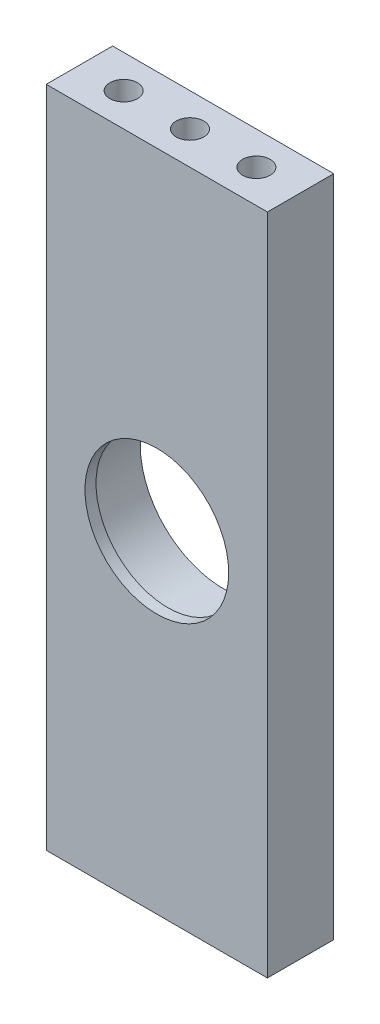
from build123d import *

# Parameters (mm, degrees)
SKETCH_1_R             = 7.5
EXTRUDE_1_DEPTH        = 6
SKETCH_2_R             = 7.5
SKETCH_2_R_2           = 6.5
EXTRUDE_3_DEPTH        = 1
HOLE_WIZARD_M3_1_D     = 2.5
HOLE_WIZARD_M3_1_DEPTH = 10
HOLE_WIZARD_M3_1_TIP   = 0.751075774
HOLE_WIZARD_M3_2_D     = 2.5
HOLE_WIZARD_M3_2_DEPTH = 10
HOLE_WIZARD_M3_2_TIP   = 0.751075774


with BuildPart() as part:
    # 스케치1 → 보스-돌출1 (new body)
    with BuildSketch(Plane.XY):
        Polygon((-7.784090909, 20.710227273), (-7.784090909, -9.289772727), (12.215909091, -9.289772727), (12.215909091, 20.710227273), (12.215909091, 50.710227273), (-7.784090909, 50.710227273), align=None)
        with Locations((2.215909091, 20.710227273)):
            Circle(SKETCH_1_R, mode=Mode.SUBTRACT)
    extrude(amount=EXTRUDE_1_DEPTH)

    # 스케치2 → 보스-돌출3 (add)
    with BuildSketch(Plane.XY.offset(6)):
        with Locations((2.215909091, 20.710227273)):
            Circle(SKETCH_2_R)
        with Locations((2.215909091, 20.710227273)):
            Circle(SKETCH_2_R_2, mode=Mode.SUBTRACT)
    extrude(amount=-EXTRUDE_3_DEPTH)

    # M3 나사 구멍1
    with Locations(Plane(origin=(0, -9.289772727, 0), x_dir=(-1, 0, 0), z_dir=(0, -1, 0))):
        with Locations((3.784090909, -3), (-2.215909091, -3), (-8.215909091, -3)):
            Hole(HOLE_WIZARD_M3_1_D / 2, depth=HOLE_WIZARD_M3_1_DEPTH)
            with Locations((0, 0, -(HOLE_WIZARD_M3_1_DEPTH + HOLE_WIZARD_M3_1_TIP / 2))):  # 118° drill point
                Cone(0, HOLE_WIZARD_M3_1_D / 2, HOLE_WIZARD_M3_1_TIP, mode=Mode.SUBTRACT)

    # M3 나사 구멍2
    with Locations(Plane(origin=(0, 50.710227273, 0), x_dir=(1, 0, 0), z_dir=(0, 1, 0))):
        with Locations((-3.784090909, -3), (2.215909091, -3), (8.215909091, -3)):
            Hole(HOLE_WIZARD_M3_2_D / 2, depth=HOLE_WIZARD_M3_2_DEPTH)
            with Locations((0, 0, -(HOLE_WIZARD_M3_2_DEPTH + HOLE_WIZARD_M3_2_TIP / 2))):  # 118° drill point
                Cone(0, HOLE_WIZARD_M3_2_D / 2, HOLE_WIZARD_M3_2_TIP, mode=Mode.SUBTRACT)


solid = part.part
